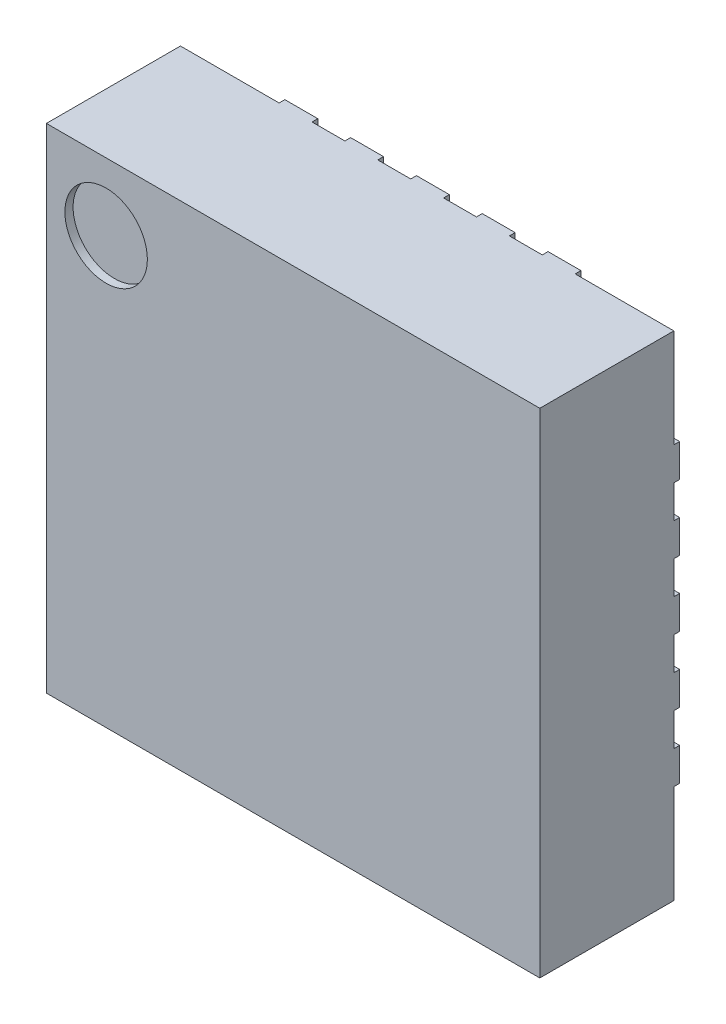
from build123d import *

# Parameters (mm, degrees)
BOSS_EXTRUDE1_START          = 0.035
SKETCH1_W                    = 3
SKETCH1_H                    = 3
BOSS_EXTRUDE1_DEPTH          = 0.815
SKETCH2_R                    = 0.250796372
CUT_EXTRUDE3_DEPTH           = 0.05
SKETCH3_W                    = 0.4
SKETCH3_H                    = 0.2
BOSS_EXTRUDE2_DEPTH          = 0.035
LPATTERN1_COUNT              = 5
LPATTERN1_PITCH              = 0.4
CUT_EXTRUDE4_DEPTH           = 0.035
CIRPATTERN1_COUNT            = 4
CIRPATTERN1_COPY_1_SKETCH_W  = 0.4
CIRPATTERN1_COPY_1_SKETCH_H  = 0.2
CIRPATTERN1_COPY_1_DEPTH     = 0.035
CIRPATTERN1_COPY_2_SKETCH_W  = 0.4
CIRPATTERN1_COPY_2_SKETCH_H  = 0.2
CIRPATTERN1_COPY_2_DEPTH     = 0.035
CIRPATTERN1_COPY_3_SKETCH_W  = 0.4
CIRPATTERN1_COPY_3_SKETCH_H  = 0.2
CIRPATTERN1_COPY_3_DEPTH     = 0.035
CIRPATTERN1_COPY_4_SKETCH_W  = 0.4
CIRPATTERN1_COPY_4_SKETCH_H  = 0.2
CIRPATTERN1_COPY_4_DEPTH     = 0.035
CIRPATTERN1_COPY_5_SKETCH_W  = 0.4
CIRPATTERN1_COPY_5_SKETCH_H  = 0.2
CIRPATTERN1_COPY_5_DEPTH     = 0.035
CIRPATTERN1_COPY_6_SKETCH_W  = 0.4
CIRPATTERN1_COPY_6_SKETCH_H  = 0.2
CIRPATTERN1_COPY_6_DEPTH     = 0.035
CIRPATTERN1_COPY_7_SKETCH_W  = 0.4
CIRPATTERN1_COPY_7_SKETCH_H  = 0.2
CIRPATTERN1_COPY_7_DEPTH     = 0.035
CIRPATTERN1_COPY_8_SKETCH_W  = 0.4
CIRPATTERN1_COPY_8_SKETCH_H  = 0.2
CIRPATTERN1_COPY_8_DEPTH     = 0.035
CIRPATTERN1_COPY_9_SKETCH_W  = 0.4
CIRPATTERN1_COPY_9_SKETCH_H  = 0.2
CIRPATTERN1_COPY_9_DEPTH     = 0.035
CIRPATTERN1_COPY_10_SKETCH_W = 0.4
CIRPATTERN1_COPY_10_SKETCH_H = 0.2
CIRPATTERN1_COPY_10_DEPTH    = 0.035
CIRPATTERN1_COPY_11_SKETCH_W = 0.4
CIRPATTERN1_COPY_11_SKETCH_H = 0.2
CIRPATTERN1_COPY_11_DEPTH    = 0.035
CIRPATTERN1_COPY_12_SKETCH_W = 0.4
CIRPATTERN1_COPY_12_SKETCH_H = 0.2
CIRPATTERN1_COPY_12_DEPTH    = 0.035
BOSS_EXTRUDE3_DEPTH          = 0.035


with BuildPart() as part:
    # Sketch1 → Boss-Extrude1 (new body)
    with BuildSketch(Plane.XY.offset(BOSS_EXTRUDE1_START)):
        Rectangle(SKETCH1_W, SKETCH1_H)
    extrude(amount=BOSS_EXTRUDE1_DEPTH)

    # Sketch2 → Cut-Extrude3 (cut)
    with BuildSketch(Plane.XY.offset(0.85)):
        with Locations((-1.136881167, 1.09046913)):
            Circle(SKETCH2_R)
    extrude(amount=-CUT_EXTRUDE3_DEPTH, mode=Mode.SUBTRACT)

    # Sketch3 → Boss-Extrude2 (add)
    with BuildSketch(Plane(origin=(0, 0, 0.035), x_dir=(-1, 0, 0), z_dir=(0, 0, -1))):
        with Locations((1.3, 0.8)):
            Rectangle(SKETCH3_W, SKETCH3_H)
    boss_extrude2 = extrude(amount=BOSS_EXTRUDE2_DEPTH)

    # LPattern1: Boss-Extrude2 ×5
    with Locations(*[(0, -i * LPATTERN1_PITCH, 0) for i in range(1, LPATTERN1_COUNT)]):
        add(boss_extrude2)

    # Sketch4 → Cut-Extrude4 (cut)
    with BuildSketch(Plane(origin=(0, 0, 0), x_dir=(-1, 0, 0), z_dir=(0, 0, -1))):
        Polygon((1.202167592, 0.9), (1.1, 0.8), (1.1, 0.9), align=None)
    cut_extrude4 = extrude(amount=-CUT_EXTRUDE4_DEPTH, mode=Mode.SUBTRACT)

    # Mirror1: Cut-Extrude4 across plane
    add(cut_extrude4.mirror(Plane.ZX), mode=Mode.SUBTRACT)

    # CirPattern1: Boss-Extrude2, Cut-Extrude4 ×4 about axis
    cirpattern1_axis = Axis((0, 0, 0), (0, 0, 1))
    add([boss_extrude2.rotate(cirpattern1_axis, i * 360 / CIRPATTERN1_COUNT) for i in range(1, CIRPATTERN1_COUNT)])
    add([cut_extrude4.rotate(cirpattern1_axis, i * 360 / CIRPATTERN1_COUNT) for i in range(1, CIRPATTERN1_COUNT)], mode=Mode.SUBTRACT)

    # CirPattern1 copy 1 sketch → CirPattern1 copy 1 (add)
    with BuildSketch(Plane(origin=(0.4, 0, 0.035), x_dir=(0, -1, 0), z_dir=(0, 0, -1))):
        with Locations((1.3, 0.8)):
            Rectangle(CIRPATTERN1_COPY_1_SKETCH_W, CIRPATTERN1_COPY_1_SKETCH_H)
    extrude(amount=CIRPATTERN1_COPY_1_DEPTH)

    # CirPattern1 copy 2 sketch → CirPattern1 copy 2 (add)
    with BuildSketch(Plane(origin=(0, 0.4, 0.035), x_dir=(1, 0, 0), z_dir=(0, 0, -1))):
        with Locations((1.3, 0.8)):
            Rectangle(CIRPATTERN1_COPY_2_SKETCH_W, CIRPATTERN1_COPY_2_SKETCH_H)
    extrude(amount=CIRPATTERN1_COPY_2_DEPTH)

    # CirPattern1 copy 3 sketch → CirPattern1 copy 3 (add)
    with BuildSketch(Plane(origin=(-0.4, 0, 0.035), x_dir=(0, 1, 0), z_dir=(0, 0, -1))):
        with Locations((1.3, 0.8)):
            Rectangle(CIRPATTERN1_COPY_3_SKETCH_W, CIRPATTERN1_COPY_3_SKETCH_H)
    extrude(amount=CIRPATTERN1_COPY_3_DEPTH)

    # CirPattern1 copy 4 sketch → CirPattern1 copy 4 (add)
    with BuildSketch(Plane(origin=(0.8, 0, 0.035), x_dir=(0, -1, 0), z_dir=(0, 0, -1))):
        with Locations((1.3, 0.8)):
            Rectangle(CIRPATTERN1_COPY_4_SKETCH_W, CIRPATTERN1_COPY_4_SKETCH_H)
    extrude(amount=CIRPATTERN1_COPY_4_DEPTH)

    # CirPattern1 copy 5 sketch → CirPattern1 copy 5 (add)
    with BuildSketch(Plane(origin=(0, 0.8, 0.035), x_dir=(1, 0, 0), z_dir=(0, 0, -1))):
        with Locations((1.3, 0.8)):
            Rectangle(CIRPATTERN1_COPY_5_SKETCH_W, CIRPATTERN1_COPY_5_SKETCH_H)
    extrude(amount=CIRPATTERN1_COPY_5_DEPTH)

    # CirPattern1 copy 6 sketch → CirPattern1 copy 6 (add)
    with BuildSketch(Plane(origin=(-0.8, 0, 0.035), x_dir=(0, 1, 0), z_dir=(0, 0, -1))):
        with Locations((1.3, 0.8)):
            Rectangle(CIRPATTERN1_COPY_6_SKETCH_W, CIRPATTERN1_COPY_6_SKETCH_H)
    extrude(amount=CIRPATTERN1_COPY_6_DEPTH)

    # CirPattern1 copy 7 sketch → CirPattern1 copy 7 (add)
    with BuildSketch(Plane(origin=(1.2, 0, 0.035), x_dir=(0, -1, 0), z_dir=(0, 0, -1))):
        with Locations((1.3, 0.8)):
            Rectangle(CIRPATTERN1_COPY_7_SKETCH_W, CIRPATTERN1_COPY_7_SKETCH_H)
    extrude(amount=CIRPATTERN1_COPY_7_DEPTH)

    # CirPattern1 copy 8 sketch → CirPattern1 copy 8 (add)
    with BuildSketch(Plane(origin=(0, 1.2, 0.035), x_dir=(1, 0, 0), z_dir=(0, 0, -1))):
        with Locations((1.3, 0.8)):
            Rectangle(CIRPATTERN1_COPY_8_SKETCH_W, CIRPATTERN1_COPY_8_SKETCH_H)
    extrude(amount=CIRPATTERN1_COPY_8_DEPTH)

    # CirPattern1 copy 9 sketch → CirPattern1 copy 9 (add)
    with BuildSketch(Plane(origin=(-1.2, 0, 0.035), x_dir=(0, 1, 0), z_dir=(0, 0, -1))):
        with Locations((1.3, 0.8)):
            Rectangle(CIRPATTERN1_COPY_9_SKETCH_W, CIRPATTERN1_COPY_9_SKETCH_H)
    extrude(amount=CIRPATTERN1_COPY_9_DEPTH)

    # CirPattern1 copy 10 sketch → CirPattern1 copy 10 (add)
    with BuildSketch(Plane(origin=(1.6, 0, 0.035), x_dir=(0, -1, 0), z_dir=(0, 0, -1))):
        with Locations((1.3, 0.8)):
            Rectangle(CIRPATTERN1_COPY_10_SKETCH_W, CIRPATTERN1_COPY_10_SKETCH_H)
    extrude(amount=CIRPATTERN1_COPY_10_DEPTH)

    # CirPattern1 copy 11 sketch → CirPattern1 copy 11 (add)
    with BuildSketch(Plane(origin=(0, 1.6, 0.035), x_dir=(1, 0, 0), z_dir=(0, 0, -1))):
        with Locations((1.3, 0.8)):
            Rectangle(CIRPATTERN1_COPY_11_SKETCH_W, CIRPATTERN1_COPY_11_SKETCH_H)
    extrude(amount=CIRPATTERN1_COPY_11_DEPTH)

    # CirPattern1 copy 12 sketch → CirPattern1 copy 12 (add)
    with BuildSketch(Plane(origin=(-1.6, 0, 0.035), x_dir=(0, 1, 0), z_dir=(0, 0, -1))):
        with Locations((1.3, 0.8)):
            Rectangle(CIRPATTERN1_COPY_12_SKETCH_W, CIRPATTERN1_COPY_12_SKETCH_H)
    extrude(amount=CIRPATTERN1_COPY_12_DEPTH)

    # Sketch5 → Boss-Extrude3 (add)
    with BuildSketch(Plane(origin=(0, 0, 0.035), x_dir=(-1, 0, 0), z_dir=(0, 0, -1))):
        Polygon((0.513555447, 0.85), (0.85, 0.513555447), (0.85, -0.85), (-0.85, -0.85), (-0.85, 0.85), align=None)
    extrude(amount=BOSS_EXTRUDE3_DEPTH)


solid = part.part
